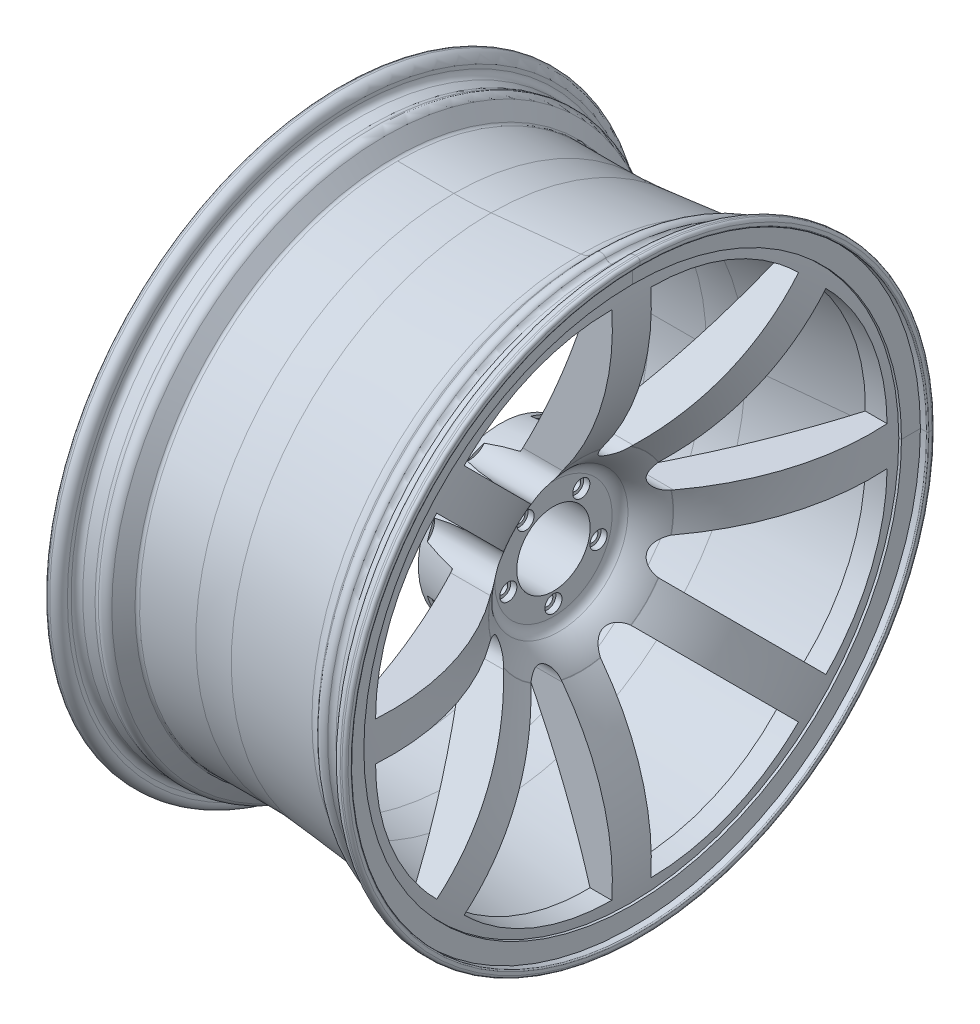
from build123d import *

# Parameters (mm, degrees)
FILLET1_R                                    = 1
FILLET2_R                                    = 15
FILLET3_R                                    = 5
FILLET4_R                                    = 7.5
FILLET5_R                                    = 2.5
FILLET6_R                                    = 1
FILLET7_R                                    = 1
CUT_EXTRUDE1_DEPTH                           = 202.184
CBORE_FOR_M8_CHEESE_SLOTTED_HEAD2_AT_2_COUNT = 2
CBORE_FOR_M8_CHEESE_SLOTTED_HEAD2_AT_2_PITCH = 45.606443917
CBORE_FOR_M8_CHEESE_SLOTTED_HEAD2_AT_3_COUNT = 2
CBORE_FOR_M8_CHEESE_SLOTTED_HEAD2_AT_3_PITCH = 73.792776364
CBORE_FOR_M8_CHEESE_SLOTTED_HEAD2_AT_4_COUNT = 2
CBORE_FOR_M8_CHEESE_SLOTTED_HEAD2_AT_4_PITCH = 73.792776364
CBORE_FOR_M8_CHEESE_SLOTTED_HEAD2_AT_5_COUNT = 2
CBORE_FOR_M8_CHEESE_SLOTTED_HEAD2_AT_5_PITCH = 45.606443917
FILLET8_R                                    = 2.54


with BuildPart() as part:
    # Sketch1 → Revolve3 (revolve)
    with BuildSketch(Plane.XY, mode=Mode.PRIVATE) as revolve3_sk:
        with BuildLine():
            ThreePointArc((-126.685531051, 219.977447732), (-130.648508738, 221.931772052), (-132.25, 226.05))
            Line((-132.25, 226.05), (-132.25, 234.163248654))
            Line((-132.25, 234.163248654), (-137.25, 237.05))
            Line((-137.25, 237.05), (-137.25, 238.8))
            ThreePointArc((-137.25, 238.8), (-136.517766953, 240.567766953), (-134.75, 241.3))
            Line((-134.75, 241.3), (-133.25, 241.3))
            ThreePointArc((-133.25, 241.3), (-128.123475836, 239.176524164), (-126, 234.05))
            Line((-126, 234.05), (-126, 231.023956351))
            ThreePointArc((-126, 231.023956351), (-124.686386684, 227.646005313), (-121.435778714, 226.04298286))
            Line((-121.435778714, 226.04298286), (-112.200916646, 225.23503712))
            ThreePointArc((-112.200916646, 225.23503712), (-110.501058498, 225.303581478), (-108.873525712, 225.798912762))
            ThreePointArc((-108.873525712, 225.798912762), (-104.14325562, 226.165159393), (-100.26593569, 223.430935206))
            Line((-100.26593569, 223.430935206), (-92.457456133, 212.279270691))
            ThreePointArc((-92.457456133, 212.279270691), (-91.38524584, 211.3389675), (-90, 211))
            Line((-90, 211), (-90, 206.5))
            ThreePointArc((-90, 206.5), (-94.303433707, 207.473347335), (-97.769120268, 210.203908335))
            Line((-97.769120268, 210.203908335), (-102.237542317, 215.923227745))
            ThreePointArc((-102.237542317, 215.923227745), (-104.102654277, 217.502161569), (-106.442672382, 218.206427081))
            Line((-106.442672382, 218.206427081), (-126.685531051, 219.977447732))
        make_face()
    revolve(revolve3_sk.sketch.rotate(Axis((0, 0, 0), (-1, 0, 0)), 90), axis=Axis((0, 0, 0), (-1, 0, 0)))

    # Fillet1
    fillet1_edges = [part.edges().sort_by_distance(p)[0] for p in [
        (-132.25, 0, 234.163248654),
        (-137.25, 0, 237.05),
    ]]
    fillet(fillet1_edges, radius=FILLET1_R)

    # Sweep1: sweep along a curve in space
    with BuildLine() as sweep1_path:
        ThreePointArc((-90, 0, -206.5), (-90, 146.017550315, -146.017550315), (-90, 206.5, 0))
        ThreePointArc((-90, 206.5, 0), (-90, 146.017550315, 146.017550315), (-90, 0, 206.5))
        ThreePointArc((-90, 0, 206.5), (-90, -146.017550315, 146.017550315), (-90, -206.5, 0))
        ThreePointArc((-90, -206.5, 0), (-90, -146.017550315, -146.017550315), (-90, 0, -206.5))
    # 3DSketch1 → Sweep1 (sweep)
    with BuildSketch(Plane(origin=(-90, 206.5, 0), x_dir=(0.14892667064111648, 0.9888482425386377, 2.1935427772145683e-14), z_dir=(0, 0, -1))):
        with BuildLine():
            Line((0, 0), (6.850626849, 45.487019157))
            ThreePointArc((6.850626849, 45.487019157), (9.515002911, 60.563090634), (12.942666222, 75.484148077))
            Line((12.942666222, 75.484148077), (41.865237251, 188.170003602))
            Line((41.865237251, 188.170003602), (57.158443685, 185.866751981))
            Line((57.158443685, 185.866751981), (58.051046444, 191.793485357))
            Line((58.051046444, 191.793485357), (63.944077628, 190.905958357))
            Line((63.944077628, 190.905958357), (62.231420916, 179.53420357))
            Line((62.231420916, 179.53420357), (47.645909339, 181.730871962))
            Line((47.645909339, 181.730871962), (43.747763345, 166.54322091))
            ThreePointArc((43.747763345, 166.54322091), (47.481392402, 162.734759498), (45.578852439, 157.752319738))
            Line((45.578852439, 157.752319738), (37.067145941, 151.468857325))
            Line((37.067145941, 151.468857325), (17.392483314, 74.813978059))
            ThreePointArc((17.392483314, 74.813978059), (13.964820002, 59.892920616), (11.300443941, 44.816849139))
            Line((11.300443941, 44.816849139), (4.449817091, -0.670170018))
            Line((4.449817091, -0.670170018), (0, 0))
        make_face()
    sweep(path=sweep1_path.line)

    # Fillet2
    fillet2_edges = [part.edges().sort_by_distance(p)[0] for p in [
        (65.3, -155.984948357, 155.984948357),
        (65.3, 155.984948357, -155.984948357),
    ]]
    fillet(fillet2_edges, radius=FILLET2_R)

    # Fillet3
    fillet3_edges = [part.edges().sort_by_distance(p)[0] for p in [
        (81.201180047, -159.068741438, 159.068741438),
        (81.201180047, 159.068741438, -159.068741438),
        (96.800000003, 160.195041278, -160.195041278),
        (96.800000003, -160.195041278, 160.195041278),
    ]]
    fillet(fillet3_edges, radius=FILLET3_R)

    # Fillet4
    fillet4_edges = [part.edges().sort_by_distance(p)[0] for p in [
        (96.800000003, 241.3, 0),
        (96.800000003, 241.3, 0),
    ]]
    fillet(fillet4_edges, radius=FILLET4_R)

    # Fillet5
    fillet5_edges = [part.edges().sort_by_distance(p)[0] for p in [
        (108.3, 241.3, 0),
        (108.3, 241.3, 0),
    ]]
    fillet(fillet5_edges, radius=FILLET5_R)

    # Fillet6
    fillet6_edges = [part.edges().sort_by_distance(p)[0] for p in [
        (108.3, 235.340510029, 0),
        (108.3, 235.340510029, 0),
    ]]
    fillet(fillet6_edges, radius=FILLET6_R)


with BuildPart() as body_2:
    # Sketch2 → Revolve5 (revolve)
    with BuildSketch(Plane.XY, mode=Mode.PRIVATE) as revolve5_sk:
        with BuildLine():
            Line((26.75, 73.567360047), (-5.75, 67.25))
            Line((-5.75, 67.25), (-5.75, 30))
            Line((-5.75, 30), (37.5, 30))
            Line((37.5, 30), (37.5, 48))
            ThreePointArc((37.5, 48), (38.694614862, 52.802343178), (42, 56.485281374))
            ThreePointArc((42, 56.485281374), (52.033414903, 65.010533642), (59.990828827, 75.5))
            ThreePointArc((59.990828827, 75.5), (94.316470097, 143.62518664), (100.324761755, 219.67248202))
            Line((100.324761755, 219.67248202), (99.125, 230.05))
            ThreePointArc((99.125, 230.05), (97.12763018, 225.23086361), (92.30791944, 223.23488011))
            Line((92.30791944, 223.23488011), (87.184770597, 223.23488011))
            ThreePointArc((87.184770597, 223.23488011), (61.29567747, 146.653383867), (26.75, 73.567360047))
        make_face()
    revolve(revolve5_sk.sketch.rotate(Axis((0, 0, 0), (-1, 0, 0)), 90), axis=Axis((0, 0, 0), (-1, 0, 0)))

    # Fillet7
    fillet7_edges = [body_2.edges().sort_by_distance(p)[0] for p in [
        (26.75, 0, 73.567360047),
    ]]
    fillet(fillet7_edges, radius=FILLET7_R)

    # Sketch3 → Cut-Extrude1 (cut)
    with BuildSketch(Plane(origin=(0, 0, 0), x_dir=(0, 0, -1), z_dir=(1, 0, 0))):
        with BuildLine():
            Line((-15.926010696, 209.184917258), (-15.926010696, 74.935333899))
            ThreePointArc((-15.926010696, 74.935333899), (-25.28008021, 60.93597956), (-41.79344458, 64.22069196))
            Line((-41.79344458, 64.22069196), (-136.722235345, 159.149482725))
            ThreePointArc((-136.722235345, 159.149482725), (-81.300456388, 196.1811315), (-15.926010696, 209.184917258))
        make_face()
        with BuildLine():
            Line((-209.184917258, 15.926010696), (-74.935333899, 15.926010696))
            ThreePointArc((-74.935333899, 15.926010696), (-60.93597956, 25.28008021), (-64.22069196, 41.79344458))
            Line((-64.22069196, 41.79344458), (-159.149482725, 136.722235345))
            ThreePointArc((-159.149482725, 136.722235345), (-196.1811315, 81.300456388), (-209.184917258, 15.926010696))
        make_face()
        with BuildLine():
            Line((-41.79344458, -64.22069196), (-136.722235345, -159.149482725))
            ThreePointArc((-136.722235345, -159.149482725), (-81.300456388, -196.1811315), (-15.926010696, -209.184917258))
            Line((-15.926010696, -209.184917258), (-15.926010696, -74.935333899))
            ThreePointArc((-15.926010696, -74.935333899), (-25.28008021, -60.93597956), (-41.79344458, -64.22069196))
        make_face()
        with BuildLine():
            Line((-64.22069196, -41.79344458), (-159.149482725, -136.722235345))
            ThreePointArc((-159.149482725, -136.722235345), (-196.1811315, -81.300456388), (-209.184917258, -15.926010696))
            Line((-209.184917258, -15.926010696), (-74.935333899, -15.926010696))
            ThreePointArc((-74.935333899, -15.926010696), (-60.93597956, -25.28008021), (-64.22069196, -41.79344458))
        make_face()
        with BuildLine():
            Line((15.926010696, -209.184917258), (15.926010696, -74.935333899))
            ThreePointArc((15.926010696, -74.935333899), (25.28008021, -60.93597956), (41.79344458, -64.22069196))
            Line((41.79344458, -64.22069196), (136.722235345, -159.149482725))
            ThreePointArc((136.722235345, -159.149482725), (81.300456388, -196.1811315), (15.926010696, -209.184917258))
        make_face()
        with BuildLine():
            Line((64.22069196, -41.79344458), (159.149482725, -136.722235345))
            ThreePointArc((159.149482725, -136.722235345), (196.1811315, -81.300456388), (209.184917258, -15.926010696))
            Line((209.184917258, -15.926010696), (74.935333899, -15.926010696))
            ThreePointArc((74.935333899, -15.926010696), (60.93597956, -25.28008021), (64.22069196, -41.79344458))
        make_face()
        with BuildLine():
            Line((209.184917258, 15.926010696), (74.935333899, 15.926010696))
            ThreePointArc((74.935333899, 15.926010696), (60.93597956, 25.28008021), (64.22069196, 41.79344458))
            Line((64.22069196, 41.79344458), (159.149482725, 136.722235345))
            ThreePointArc((159.149482725, 136.722235345), (196.1811315, 81.300456388), (209.184917258, 15.926010696))
        make_face()
        with BuildLine():
            Line((41.79344458, 64.22069196), (136.722235345, 159.149482725))
            ThreePointArc((136.722235345, 159.149482725), (81.300456388, 196.1811315), (15.926010696, 209.184917258))
            Line((15.926010696, 209.184917258), (15.926010696, 74.935333899))
            ThreePointArc((15.926010696, 74.935333899), (25.28008021, 60.93597956), (41.79344458, 64.22069196))
        make_face()
    extrude(amount=CUT_EXTRUDE1_DEPTH, mode=Mode.SUBTRACT)

    # Sketch11 → CBORE for M8 Cheese Slotted Head2 (revolve, cut)
    with BuildSketch(Plane(origin=(37.5, -38.795158384, 0), x_dir=(0, 0, -1), z_dir=(0, 1, 0))):
        Polygon((0, 0), (0, 174.75), (4.5, 174.75), (4.5, 5), (7, 5), (7, 0), align=None)
    cbore_for_m8_cheese_slotted_head2 = revolve(axis=Axis((43.85, -38.795158384, 0), (-1, 0, 0)), mode=Mode.SUBTRACT)

    # CBORE for M8 Cheese Slotted Head2 at 2: CBORE for M8 Cheese Slotted Head2 ×2
    with Locations(*[Vector(0, 0.5877852522924731, 0.8090169943749476) * (i * CBORE_FOR_M8_CHEESE_SLOTTED_HEAD2_AT_2_PITCH) for i in range(1, CBORE_FOR_M8_CHEESE_SLOTTED_HEAD2_AT_2_COUNT)]):
        add(cbore_for_m8_cheese_slotted_head2, mode=Mode.SUBTRACT)

    # CBORE for M8 Cheese Slotted Head2 at 3: CBORE for M8 Cheese Slotted Head2 ×2
    with Locations(*[Vector(0, 0.9510565162951536, 0.3090169943749475) * (i * CBORE_FOR_M8_CHEESE_SLOTTED_HEAD2_AT_3_PITCH) for i in range(1, CBORE_FOR_M8_CHEESE_SLOTTED_HEAD2_AT_3_COUNT)]):
        add(cbore_for_m8_cheese_slotted_head2, mode=Mode.SUBTRACT)

    # CBORE for M8 Cheese Slotted Head2 at 4: CBORE for M8 Cheese Slotted Head2 ×2
    with Locations(*[Vector(0, 0.9510565162951536, -0.3090169943749474) * (i * CBORE_FOR_M8_CHEESE_SLOTTED_HEAD2_AT_4_PITCH) for i in range(1, CBORE_FOR_M8_CHEESE_SLOTTED_HEAD2_AT_4_COUNT)]):
        add(cbore_for_m8_cheese_slotted_head2, mode=Mode.SUBTRACT)

    # CBORE for M8 Cheese Slotted Head2 at 5: CBORE for M8 Cheese Slotted Head2 ×2
    with Locations(*[Vector(0, 0.5877852522924732, -0.8090169943749475) * (i * CBORE_FOR_M8_CHEESE_SLOTTED_HEAD2_AT_5_PITCH) for i in range(1, CBORE_FOR_M8_CHEESE_SLOTTED_HEAD2_AT_5_COUNT)]):
        add(cbore_for_m8_cheese_slotted_head2, mode=Mode.SUBTRACT)

    # Fillet8
    fillet8_edges = [body_2.edges().sort_by_distance(p)[0] for p in [
        (59.990828827, 53.38656198, -53.38656198),
        (59.990828827, 75.5, 0),
        (59.990828827, 53.38656198, 53.38656198),
        (59.990828827, 0, 75.5),
        (59.990828827, -53.38656198, 53.38656198),
        (59.990828827, -75.5, 0),
        (59.990828827, -53.38656198, -53.38656198),
        (59.990828827, -8.030159124, -75.07174265),
    ]]
    fillet(fillet8_edges, radius=FILLET8_R)


solid = Compound([part.part, body_2.part])
